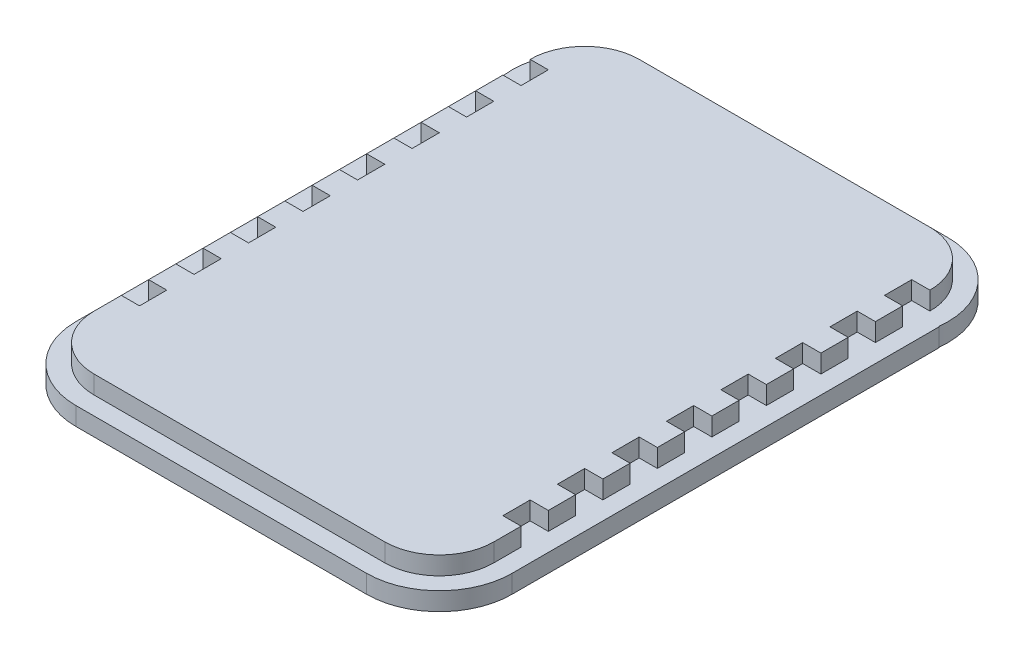
from build123d import *

# Parameters (mm, degrees)
SKETCH1_W           = 220
SKETCH1_H           = 300
BOSS_EXTRUDE1_DEPTH = 10
FILLET1_R           = 30
SKETCH9_W           = 15
SKETCH9_H           = 10
CUT_EXTRUDE1_DEPTH  = 10
SKETCH8_W           = 15
SKETCH8_H           = 10
CUT_EXTRUDE2_DEPTH  = 10
BOSS_EXTRUDE3_DEPTH = 10


with BuildPart() as part:
    # Sketch1 → Boss-Extrude1 (new body)
    with BuildSketch(Plane(origin=(0, 0, 0), x_dir=(1, 0, 0), z_dir=(0, 1, 0))):
        with Locations((110, 150)):
            Rectangle(SKETCH1_W, SKETCH1_H)
    extrude(amount=BOSS_EXTRUDE1_DEPTH)

    # Fillet1
    fillet1_edges = [part.edges().sort_by_distance(p)[0] for p in [
        (0, 5, -300),
        (220, 5, -300),
        (220, 5, 0),
        (0, 5, 0),
    ]]
    fillet(fillet1_edges, radius=FILLET1_R)

    # Sketch9 → Cut-Extrude1 (cut)
    with BuildSketch(Plane(origin=(220, 0, 0), x_dir=(0, 0, -1), z_dir=(1, 0, 0))):
        with Locations((262.5, 5)):
            Rectangle(SKETCH9_W, SKETCH9_H)
        with Locations((232.5, 5)):
            Rectangle(SKETCH9_W, SKETCH9_H)
        with Locations((202.5, 5)):
            Rectangle(SKETCH9_W, SKETCH9_H)
        with Locations((172.5, 5)):
            Rectangle(SKETCH9_W, SKETCH9_H)
        with Locations((142.5, 5)):
            Rectangle(SKETCH9_W, SKETCH9_H)
        with Locations((112.5, 5)):
            Rectangle(SKETCH9_W, SKETCH9_H)
        with Locations((82.5, 5)):
            Rectangle(SKETCH9_W, SKETCH9_H)
        with Locations((52.5, 5)):
            Rectangle(SKETCH9_W, SKETCH9_H)
    extrude(amount=-CUT_EXTRUDE1_DEPTH, mode=Mode.SUBTRACT)

    # Sketch8 → Cut-Extrude2 (cut)
    with BuildSketch(Plane.ZY):
        with Locations((-262.5, 5)):
            Rectangle(SKETCH8_W, SKETCH8_H)
        with Locations((-232.5, 5)):
            Rectangle(SKETCH8_W, SKETCH8_H)
        with Locations((-202.5, 5)):
            Rectangle(SKETCH8_W, SKETCH8_H)
        with Locations((-172.5, 5)):
            Rectangle(SKETCH8_W, SKETCH8_H)
        with Locations((-142.5, 5)):
            Rectangle(SKETCH8_W, SKETCH8_H)
        with Locations((-112.5, 5)):
            Rectangle(SKETCH8_W, SKETCH8_H)
        with Locations((-82.5, 5)):
            Rectangle(SKETCH8_W, SKETCH8_H)
        with Locations((-52.5, 5)):
            Rectangle(SKETCH8_W, SKETCH8_H)
    extrude(amount=-CUT_EXTRUDE2_DEPTH, mode=Mode.SUBTRACT)

    # Sketch11 → Boss-Extrude3 (add)
    with BuildSketch(Plane.XZ):
        with BuildLine():
            Line((229.686269666, -265), (230, -265))
            Line((230, -265), (230, -30))
            ThreePointArc((230, -30), (218.284271247, -1.715728753), (190, 10))
            Line((190, 10), (30, 10))
            ThreePointArc((30, 10), (1.715728753, -1.715728753), (-10, -30))
            Line((-10, -30), (-10, -265))
            Line((-10, -265), (-9.686269666, -265))
            ThreePointArc((-9.686269666, -265), (0, -296.457513111), (30, -310))
            Line((30, -310), (190, -310))
            ThreePointArc((190, -310), (220, -296.457513111), (229.686269666, -265))
        make_face()
    extrude(amount=BOSS_EXTRUDE3_DEPTH)


solid = part.part
